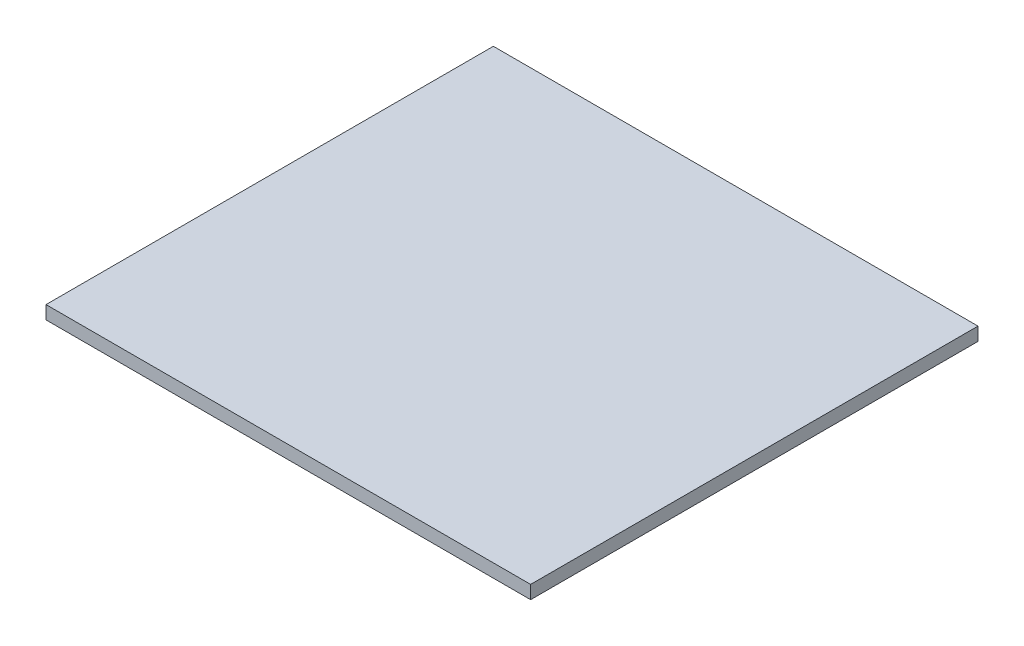
from build123d import *

# Parameters (mm, degrees)
SKETCH2_W           = 82.55
SKETCH2_H           = 76.2
BOSS_EXTRUDE1_DEPTH = 2.2606


with BuildPart() as part:
    # Sketch2 → Boss-Extrude1 (new body)
    with BuildSketch(Plane(origin=(0, 0, 0), x_dir=(1, 0, 0), z_dir=(0, 1, 0))):
        with Locations((-77.312048433, 27.033489416)):
            Rectangle(SKETCH2_W, SKETCH2_H)
    extrude(amount=BOSS_EXTRUDE1_DEPTH)


solid = part.part
